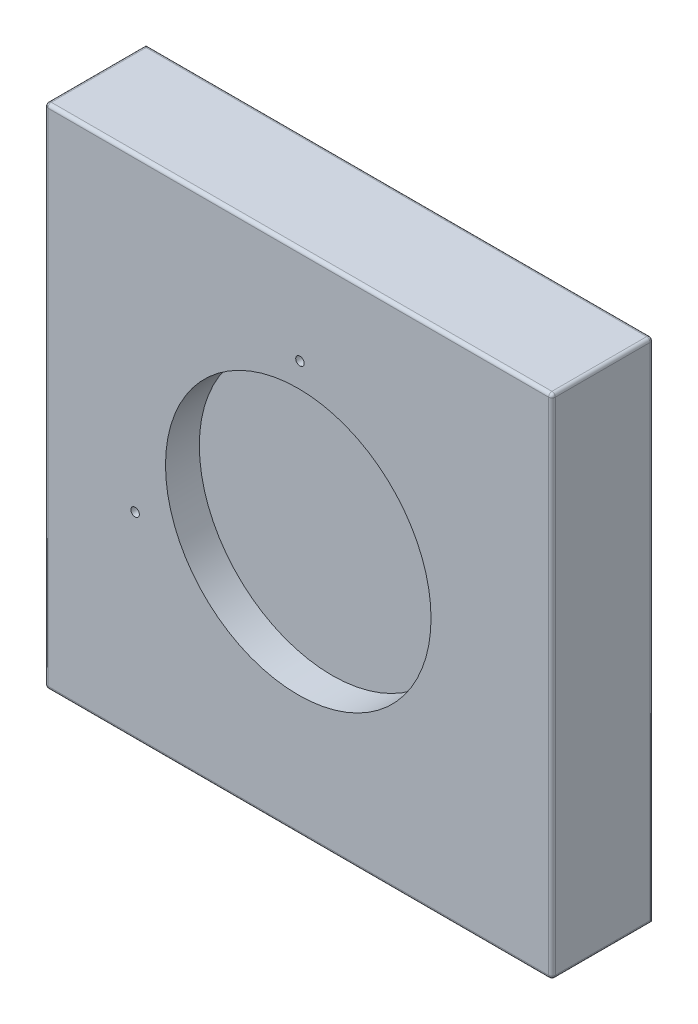
from build123d import *

# Parameters (mm, degrees)
SKETCH1_W                       = 150
SKETCH1_H                       = 150
BOSS_EXTRUDE1_DEPTH             = 30
FILLET1_R                       = 1
SKETCH2_R                       = 39.25
CUT_EXTRUDE4_DEPTH              = 10
TAP_DRILL_FOR_M3X0_5_TAP3_D     = 2.5
TAP_DRILL_FOR_M3X0_5_TAP3_DEPTH = 10
TAP_DRILL_FOR_M3X0_5_TAP3_TIP   = 0.751075774


with BuildPart() as part:
    # Sketch1 → Boss-Extrude1 (new body)
    with BuildSketch(Plane.XY):
        Rectangle(SKETCH1_W, SKETCH1_H)
    extrude(amount=-BOSS_EXTRUDE1_DEPTH)

    # Fillet1
    fillet1_edges = [part.edges().sort_by_distance(p)[0] for p in [
        (75, -75, -15),
        (-75, -75, -15),
        (-75, 75, -15),
        (75, 0, -30),
        (0, 75, -30),
        (75, 75, -15),
        (0, -75, 0),
        (-75, 0, 0),
        (75, 0, 0),
        (0, 75, 0),
    ]]
    fillet(fillet1_edges, radius=FILLET1_R)

    # Sketch2 → Cut-Extrude4 (cut)
    with BuildSketch(Plane.XY):
        Circle(SKETCH2_R)
    extrude(amount=-CUT_EXTRUDE4_DEPTH, mode=Mode.SUBTRACT)

    # Tap Drill for M3x0.5 Tap3
    with Locations(Plane.XY):
        with Locations((0.496213053, 46.5), (-48.237547134, -16.547252974)):
            Hole(TAP_DRILL_FOR_M3X0_5_TAP3_D / 2, depth=TAP_DRILL_FOR_M3X0_5_TAP3_DEPTH)
            with Locations((0, 0, -(TAP_DRILL_FOR_M3X0_5_TAP3_DEPTH + TAP_DRILL_FOR_M3X0_5_TAP3_TIP / 2))):  # 118° drill point
                Cone(0, TAP_DRILL_FOR_M3X0_5_TAP3_D / 2, TAP_DRILL_FOR_M3X0_5_TAP3_TIP, mode=Mode.SUBTRACT)


solid = part.part
